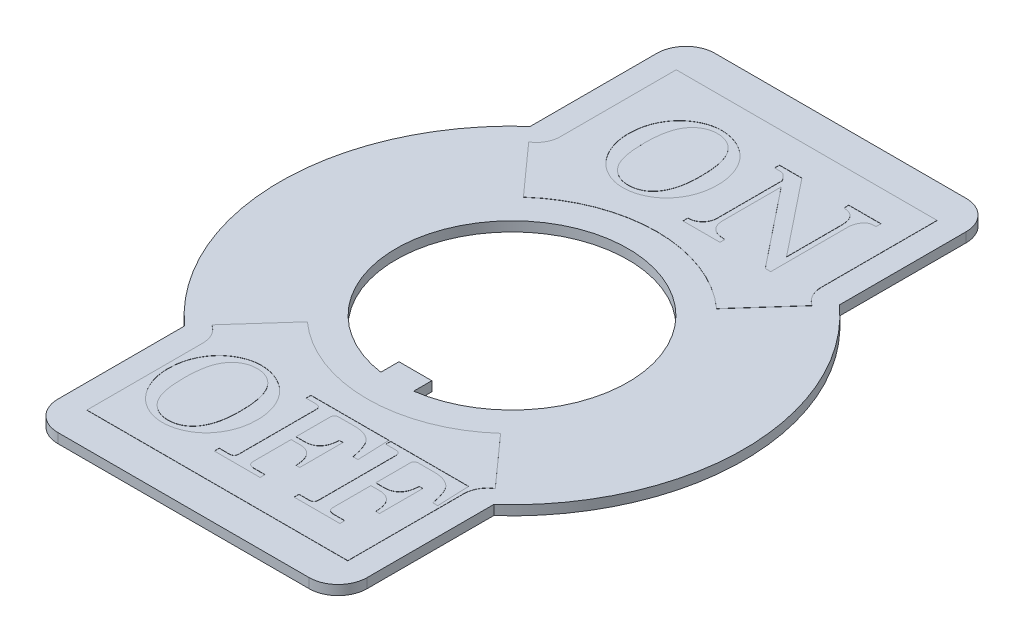
from build123d import *

# Parameters (mm, degrees)
BOSS_EXTRUDE1_DEPTH = 0.5
BOSS_EXTRUDE2_DEPTH = 0.01
CUT_EXTRUDE1_DEPTH  = 0.01


with BuildPart() as part:
    # Sketch1 → Boss-Extrude1 (new body)
    with BuildSketch(Plane(origin=(0, 0, 0), x_dir=(1, 0, 0), z_dir=(0, 1, 0))):
        with BuildLine():
            ThreePointArc((8, 15.5), (7.560660172, 16.560660172), (6.5, 17))
            Line((6.5, 17), (-6.5, 17))
            ThreePointArc((-6.5, 17), (-7.560660172, 16.560660172), (-8, 15.5))
            Line((-8, 15.5), (-8, 8.94427191))
            ThreePointArc((-8, 8.94427191), (-12, 0), (-8, -8.94427191))
            Line((-8, -8.94427191), (-8, -15.5))
            ThreePointArc((-8, -15.5), (-7.560660172, -16.560660172), (-6.5, -17))
            Line((-6.5, -17), (6.5, -17))
            ThreePointArc((6.5, -17), (7.560660172, -16.560660172), (8, -15.5))
            Line((8, -15.5), (8, -8.94427191))
            ThreePointArc((8, -8.94427191), (12, 0), (8, 8.94427191))
            Line((8, 8.94427191), (8, 15.5))
        make_face()
        with BuildLine():
            ThreePointArc((-0.85, -5.93948651), (0, 6), (0.85, -5.93948651))
            Line((0.85, -5.93948651), (0.85, -5))
            Line((0.85, -5), (-0.85, -5))
            Line((-0.85, -5), (-0.85, -5.93948651))
        make_face(mode=Mode.SUBTRACT)
    extrude(amount=BOSS_EXTRUDE1_DEPTH)

    # Sketch2 → Boss-Extrude2 (add)
    with BuildSketch(Plane(origin=(0, 0.5, 0), x_dir=(1, 0, 0), z_dir=(0, 1, 0))):
        with BuildLine():
            Line((6.75, 15.25), (-6.75, 15.25))
            Line((-6.75, 15.25), (-6.75, 9.25))
            ThreePointArc((-6.75, 9.25), (-6.905607849, 8.648947688), (-7.333333333, 8.198915917))
            Line((-7.333333333, 8.198915917), (-5, 5.590169944))
            ThreePointArc((-5, 5.590169944), (0, 7.5), (5, 5.590169944))
            Line((5, 5.590169944), (7.333333333, 8.198915917))
            ThreePointArc((7.333333333, 8.198915917), (6.905607849, 8.648947688), (6.75, 9.25))
            Line((6.75, 9.25), (6.75, 15.25))
        make_face()
        with BuildLine():
            Line((6.75, -15.25), (6.75, -9.25))
            ThreePointArc((6.75, -9.25), (6.905607849, -8.648947688), (7.333333333, -8.198915917))
            Line((7.333333333, -8.198915917), (5, -5.590169944))
            ThreePointArc((5, -5.590169944), (0, -7.5), (-5, -5.590169944))
            Line((-5, -5.590169944), (-7.333333333, -8.198915917))
            ThreePointArc((-7.333333333, -8.198915917), (-6.905607849, -8.648947688), (-6.75, -9.25))
            Line((-6.75, -9.25), (-6.75, -15.25))
            Line((-6.75, -15.25), (6.75, -15.25))
        make_face()
    extrude(amount=BOSS_EXTRUDE2_DEPTH)

    # Sketch3 → Cut-Extrude1 (cut)
    with BuildSketch(Plane(origin=(0, 0.51, 0), x_dir=(1, 0, 0), z_dir=(0, 1, 0))):
        with BuildLine():
            add(Edge.make_bspline(
                [(-2.864583333, 13.713050252), (-2.812468457, 13.712075984), (-2.709022219, 13.710142095), (-2.554972652, 13.694972601), (-2.403956212, 13.668381989), (-2.254735631, 13.633845258), (-2.10843339, 13.587084757), (-1.963809463, 13.531493439), (-1.822876473, 13.463617861), (-1.684235254, 13.387899473), (-1.551305652, 13.302190275), (-1.423973076, 13.208820824), (-1.305251073, 13.106557316), (-1.193119495, 12.99682318), (-1.089006227, 12.878643346), (-0.992800388, 12.751782549), (-0.903297195, 12.617590946), (-0.822790163, 12.47529873), (-0.749263957, 12.327546954), (-0.686522642, 12.17364314), (-0.631882058, 12.015762626), (-0.589200806, 11.852498725), (-0.55528713, 11.685286625), (-0.529656565, 11.513531463), (-0.515974008, 11.336807487), (-0.513880484, 11.217411746), (-0.512820513, 11.156960509)],
                knots=[0, 0, 0, 0, 0.00015633, 0.00031031, 0.000463778, 0.000616104, 0.000769424, 0.000924177, 0.001080537, 0.001238333, 0.001397811, 0.001554666, 0.00171165, 0.001867469, 0.002025011, 0.002183669, 0.00234479, 0.00250853, 0.002673819, 0.002839547, 0.003006788, 0.003174666, 0.003345365, 0.00351846, 0.003695299, 0.003876658, 0.003876658, 0.003876658, 0.003876658], degree=3))
            add(Edge.make_bspline(
                [(-0.512820513, 11.156960509), (-0.51373348, 11.096495605), (-0.515537073, 10.977045454), (-0.531341916, 10.800538672), (-0.554932774, 10.628552875), (-0.589103481, 10.460952248), (-0.633239722, 10.297370724), (-0.687150719, 10.138001011), (-0.751616054, 9.983675633), (-0.824492963, 9.834283927), (-0.906514185, 9.691653163), (-0.995678673, 9.556068828), (-1.092040418, 9.428597773), (-1.195399434, 9.308787155), (-1.30690416, 9.197346398), (-1.425893511, 9.094455504), (-1.552209804, 8.999654723), (-1.684248553, 8.913123543), (-1.821576978, 8.836089991), (-1.961331929, 8.7689084), (-2.103799147, 8.7127046), (-2.247407755, 8.665418002), (-2.393649003, 8.628798328), (-2.542142886, 8.604702284), (-2.692568209, 8.587338366), (-2.793753166, 8.585678454), (-2.844551282, 8.584845124)],
                knots=[0, 0, 0, 0, 0.000181359, 0.00035828, 0.000531233, 0.000701932, 0.000871037, 0.001039226, 0.001206262, 0.00137245, 0.001537556, 0.001699513, 0.001858969, 0.002016606, 0.002173835, 0.002331472, 0.002488123, 0.002647306, 0.002804713, 0.002960168, 0.003112125, 0.003263844, 0.003413485, 0.003563823, 0.003714915, 0.003867241, 0.003867241, 0.003867241, 0.003867241], degree=3))
            add(Edge.make_bspline(
                [(-2.844551282, 8.584845124), (-2.894002684, 8.585796638), (-2.992466052, 8.587691212), (-3.138714815, 8.603259452), (-3.283103116, 8.628047388), (-3.42475383, 8.66457968), (-3.564499889, 8.709401956), (-3.70175339, 8.76497853), (-3.83627043, 8.831207861), (-3.968787085, 8.906155678), (-4.096652831, 8.990749944), (-4.217744661, 9.085680944), (-4.33409882, 9.187476335), (-4.441134196, 9.300861125), (-4.545875975, 9.419285543), (-4.640116358, 9.54953776), (-4.729765374, 9.687034598), (-4.81253615, 9.832302304), (-4.886367046, 9.984697472), (-4.951748905, 10.141278074), (-5.005629541, 10.302852217), (-5.051165809, 10.467490598), (-5.084795934, 10.637003097), (-5.109904146, 10.809805286), (-5.125415266, 10.987072736), (-5.127267526, 11.106515414), (-5.128205128, 11.166976534)],
                knots=[0, 0, 0, 0, 0.000148322, 0.000295325, 0.000440727, 0.000587454, 0.000733791, 0.000880726, 0.001031237, 0.001183299, 0.001337198, 0.001490665, 0.001644629, 0.001800467, 0.001958105, 0.002118567, 0.0022822, 0.002450413, 0.00261974, 0.002789935, 0.002959073, 0.003130373, 0.003302054, 0.003477131, 0.003654052, 0.003835411, 0.003835411, 0.003835411, 0.003835411], degree=3))
            add(Edge.make_bspline(
                [(-5.128205128, 11.166976534), (-5.12717416, 11.226431314), (-5.125132533, 11.344169643), (-5.110930119, 11.518769958), (-5.087176666, 11.689077227), (-5.052789787, 11.854522497), (-5.009954847, 12.015603004), (-4.956397312, 12.171921758), (-4.894671777, 12.324464545), (-4.822570557, 12.471667642), (-4.741056379, 12.612062372), (-4.654841705, 12.747049739), (-4.558667574, 12.872402221), (-4.456715397, 12.990508553), (-4.34826719, 13.101605904), (-4.23175793, 13.203624609), (-4.108341575, 13.298081051), (-3.978558161, 13.383621168), (-3.84479677, 13.46064411), (-3.708561388, 13.527741451), (-3.571088405, 13.585020981), (-3.432727025, 13.632428977), (-3.292812682, 13.668979339), (-3.151322151, 13.693119722), (-3.008577438, 13.710566039), (-2.912713671, 13.712219899), (-2.864583333, 13.713050252)],
                knots=[0, 0, 0, 0, 0.000178356, 0.000353198, 0.000525159, 0.000693895, 0.000859838, 0.001024859, 0.001189281, 0.001353229, 0.0015161, 0.001676121, 0.001833376, 0.0019896, 0.002144003, 0.002298717, 0.002453772, 0.002609893, 0.002764689, 0.00291654, 0.003065162, 0.00321118, 0.003354996, 0.003498425, 0.003641552, 0.00378587, 0.00378587, 0.00378587, 0.00378587], degree=3))
        make_face()
        with BuildLine():
            add(Edge.make_bspline(
                [(-2.810496795, 13.456639996), (-2.864367338, 13.455339086), (-2.970431055, 13.452777772), (-3.125237932, 13.425431512), (-3.272246281, 13.383817486), (-3.411700203, 13.324889175), (-3.542705087, 13.248560704), (-3.666191688, 13.155496862), (-3.780629825, 13.04487965), (-3.8887603, 12.918645831), (-3.985364042, 12.772225919), (-4.068471624, 12.604858259), (-4.139578914, 12.417073207), (-4.19547343, 12.207432504), (-4.240739251, 11.977260711), (-4.271384157, 11.725857663), (-4.292389501, 11.453457323), (-4.294023795, 11.264843882), (-4.294871795, 11.166976534)],
                knots=[0, 0, 0, 0, 0.000161457, 0.000317887, 0.000470051, 0.000619061, 0.000770754, 0.000923799, 0.001081776, 0.001247344, 0.001421522, 0.001606518, 0.001806863, 0.002022878, 0.002256631, 0.002510068, 0.002782241, 0.003075772, 0.003075772, 0.003075772, 0.003075772], degree=3))
            add(Edge.make_bspline(
                [(-4.294871795, 11.166976534), (-4.293431121, 11.061448994), (-4.290661251, 10.858559576), (-4.272365386, 10.566917818), (-4.239630857, 10.300653677), (-4.19426956, 10.059501982), (-4.135918473, 9.843435081), (-4.064421129, 9.652181058), (-3.978375102, 9.486546743), (-3.879173122, 9.34535675), (-3.76931806, 9.226453207), (-3.653610699, 9.123806769), (-3.53247794, 9.035617151), (-3.403882619, 8.965263652), (-3.26961513, 8.909603724), (-3.128966672, 8.869176687), (-2.981537926, 8.846023553), (-2.881356061, 8.84286027), (-2.830528846, 8.84125538)],
                knots=[0, 0, 0, 0, 0.000316584, 0.000608671, 0.000876146, 0.001120906, 0.001344212, 0.001546786, 0.001732263, 0.001902609, 0.002062828, 0.002216792, 0.002366061, 0.002511307, 0.002655461, 0.002801297, 0.002949334, 0.003101789, 0.003101789, 0.003101789, 0.003101789], degree=3))
            add(Edge.make_bspline(
                [(-2.830528846, 8.84125538), (-2.794786657, 8.842179785), (-2.72450079, 8.843997596), (-2.620286136, 8.85379338), (-2.519567555, 8.871956584), (-2.422041264, 8.896813843), (-2.328164813, 8.929514729), (-2.236839276, 8.967847139), (-2.149883974, 9.015891752), (-2.065055415, 9.068525702), (-1.984418385, 9.130058039), (-1.908437235, 9.200552602), (-1.835864601, 9.279057767), (-1.767906456, 9.366191535), (-1.704892457, 9.461966101), (-1.645472788, 9.565562592), (-1.590781054, 9.677853508), (-1.53949866, 9.798352215), (-1.492831783, 9.927787875), (-1.454911439, 10.067436093), (-1.419824888, 10.216169616), (-1.394140638, 10.375306829), (-1.371334164, 10.543522053), (-1.356994196, 10.721728193), (-1.347758849, 10.909464653), (-1.34669694, 11.038091684), (-1.346153846, 11.103875573)],
                knots=[0, 0, 0, 0, 0.000107246, 0.000210896, 0.000313652, 0.000413983, 0.000512492, 0.000611655, 0.000710698, 0.00081018, 0.000910944, 0.001014434, 0.001120755, 0.001231354, 0.001345528, 0.00146442, 0.001589395, 0.001719992, 0.001857168, 0.002001767, 0.002153865, 0.0023154, 0.002485106, 0.002663025, 0.002851542, 0.00304888, 0.00304888, 0.00304888, 0.00304888], degree=3))
            add(Edge.make_bspline(
                [(-1.346153846, 11.103875573), (-1.3468274, 11.175327478), (-1.348137173, 11.31427088), (-1.355472419, 11.516773642), (-1.370981782, 11.707454808), (-1.390638707, 11.885870334), (-1.415038718, 12.052544539), (-1.447497155, 12.206448949), (-1.483822939, 12.34919998), (-1.527340026, 12.480126024), (-1.575635139, 12.601145669), (-1.628648945, 12.713647777), (-1.686815468, 12.818086891), (-1.749576902, 12.914560891), (-1.818483552, 13.002192246), (-1.89105074, 13.08231569), (-1.969164303, 13.154365994), (-2.051879258, 13.218001936), (-2.138344762, 13.273893941), (-2.226593465, 13.323655729), (-2.317863626, 13.364606569), (-2.411728887, 13.397844592), (-2.507872055, 13.423723886), (-2.606525803, 13.443149001), (-2.707752319, 13.454076417), (-2.776083891, 13.455781359), (-2.810496795, 13.456639996)],
                knots=[0, 0, 0, 0, 0.000214364, 0.000416846, 0.000607743, 0.000788145, 0.000955296, 0.001112838, 0.001259814, 0.001396961, 0.001526412, 0.001650517, 0.001769788, 0.001884798, 0.001995397, 0.002103871, 0.002208777, 0.002313754, 0.002416544, 0.002517428, 0.002617397, 0.002716237, 0.002815855, 0.00291584, 0.0030176, 0.003120843, 0.003120843, 0.003120843, 0.003120843], degree=3))
        make_face(mode=Mode.SUBTRACT)
        with BuildLine():
            Line((0.192307692, 13.648947688), (1.355168269, 13.648947688))
            Line((1.355168269, 13.648947688), (4.487179487, 9.720662432))
            Line((4.487179487, 9.720662432), (4.487179487, 12.561207304))
            add(Edge.make_bspline(
                [(4.487179487, 12.561207304), (4.486624787, 12.595946314), (4.485550715, 12.663211769), (4.476716763, 12.760339106), (4.46121445, 12.850202882), (4.44223679, 12.933793997), (4.414478561, 13.009837195), (4.383290718, 13.079853904), (4.343476631, 13.141499745), (4.312936401, 13.178150398), (4.297876603, 13.196223329)],
                knots=[0, 0, 0, 0, 0.00010421, 0.000201783, 0.000292183, 0.000377695, 0.000458478, 0.000534659, 0.000607177, 0.000677724, 0.000677724, 0.000677724, 0.000677724], degree=3))
            add(Edge.make_bspline(
                [(4.297876603, 13.196223329), (4.282831592, 13.211251544), (4.252612174, 13.241437227), (4.201087874, 13.280973307), (4.143612271, 13.313264341), (4.082213685, 13.342494203), (4.014148114, 13.36268904), (3.941565971, 13.37884088), (3.863426424, 13.388759494), (3.809788312, 13.391249707), (3.782051282, 13.392537432)],
                knots=[0, 0, 0, 0, 6.3757e-05, 0.000128063, 0.000194032, 0.000261259, 0.000331585, 0.000406438, 0.000484209, 0.000567493, 0.000567493, 0.000567493, 0.000567493], degree=3))
            Line((3.782051282, 13.392537432), (3.782051282, 13.648947688))
            Line((3.782051282, 13.648947688), (5.448717949, 13.648947688))
            Line((5.448717949, 13.648947688), (5.448717949, 13.392537432))
            add(Edge.make_bspline(
                [(5.448717949, 13.392537432), (5.40830535, 13.39145269), (5.332586338, 13.389420264), (5.226323457, 13.377904241), (5.136936702, 13.353699968), (5.06021957, 13.321895478), (4.997119481, 13.273037628), (4.937523097, 13.213577167), (4.885963966, 13.135754452), (4.836221564, 13.047245768), (4.794166, 12.948490663), (4.765949779, 12.84251325), (4.746775402, 12.732504974), (4.744663169, 12.657445213), (4.743589744, 12.619300252)],
                knots=[0, 0, 0, 0, 0.000121297, 0.000227269, 0.000319595, 0.000398513, 0.000474436, 0.000557304, 0.000650107, 0.000753229, 0.000861864, 0.00097097, 0.001081623, 0.001195964, 0.001195964, 0.001195964, 0.001195964], degree=3))
            Line((4.743589744, 12.619300252), (4.743589744, 8.648947688))
            Line((4.743589744, 8.648947688), (4.459134615, 8.648947688))
            Line((4.459134615, 8.648947688), (1.217948718, 12.713450893))
            Line((1.217948718, 12.713450893), (1.217948718, 9.717657624))
            add(Edge.make_bspline(
                [(1.217948718, 9.717657624), (1.218296578, 9.684897634), (1.218973172, 9.62117882), (1.230749382, 9.529172976), (1.247165687, 9.443182804), (1.271432417, 9.364155351), (1.301113742, 9.29068958), (1.339849959, 9.224720196), (1.383642723, 9.163845398), (1.43569531, 9.110086915), (1.494875117, 9.062817081), (1.562091331, 9.022966094), (1.635570164, 8.987382379), (1.71727022, 8.95868795), (1.806340408, 8.935496073), (1.903022288, 8.920388937), (2.006613147, 8.908736842), (2.078289851, 8.906510263), (2.115384615, 8.905357945)],
                knots=[0, 0, 0, 0, 9.8203e-05, 0.000191007, 0.000277829, 0.000360526, 0.000438651, 0.000514931, 0.000589455, 0.000663125, 0.000738678, 0.000815977, 0.000897064, 0.000983236, 0.001075308, 0.001172788, 0.00127654, 0.00138783, 0.00138783, 0.00138783, 0.00138783], degree=3))
            Line((2.115384615, 8.905357945), (2.115384615, 8.648947688))
            Line((2.115384615, 8.648947688), (0.192307692, 8.648947688))
            Line((0.192307692, 8.648947688), (0.192307692, 8.905357945))
            add(Edge.make_bspline(
                [(0.192307692, 8.905357945), (0.22106758, 8.906840271), (0.277524834, 8.90975016), (0.359718592, 8.922880489), (0.437098367, 8.942973226), (0.509819398, 8.969219664), (0.578075023, 9.001108145), (0.641926263, 9.039600463), (0.701343603, 9.084643091), (0.772271116, 9.153926021), (0.849045815, 9.24988305), (0.913932154, 9.381479678), (0.954574072, 9.524616386), (0.959184801, 9.624567703), (0.961538462, 9.675590316)],
                knots=[0, 0, 0, 0, 8.6347e-05, 0.000169504, 0.000249187, 0.00032586, 0.000401134, 0.000474825, 0.000549146, 0.000624233, 0.000771904, 0.000915242, 0.00106177, 0.00121457, 0.00121457, 0.00121457, 0.00121457], degree=3))
            Line((0.961538462, 9.675590316), (0.961538462, 13.035966919))
            Line((0.961538462, 13.035966919), (0.89443109, 13.121103137))
            add(Edge.make_bspline(
                [(0.89443109, 13.121103137), (0.871044623, 13.149776427), (0.828680691, 13.201717291), (0.767777964, 13.267366266), (0.718492584, 13.316398433), (0.68508654, 13.336873459), (0.671073718, 13.345462111)],
                knots=[0, 0, 0, 0, 0.000110929, 0.000200946, 0.000268996, 0.000318166, 0.000318166, 0.000318166, 0.000318166], degree=3))
            add(Edge.make_bspline(
                [(0.671073718, 13.345462111), (0.653913124, 13.353072618), (0.618197195, 13.368912183), (0.557680137, 13.381627356), (0.490761519, 13.391146514), (0.443419924, 13.392059911), (0.418669872, 13.392537432)],
                knots=[0, 0, 0, 0, 5.617e-05, 0.000116906, 0.000184616, 0.000258795, 0.000258795, 0.000258795, 0.000258795], degree=3))
            Line((0.418669872, 13.392537432), (0.192307692, 13.392537432))
            Line((0.192307692, 13.392537432), (0.192307692, 13.648947688))
        make_face()
        with BuildLine():
            add(Edge.make_bspline(
                [(-4.250079566, -8.726817902), (-4.197964689, -8.72779217), (-4.094518452, -8.729726059), (-3.940468884, -8.744895553), (-3.789452444, -8.771486165), (-3.640231863, -8.806022896), (-3.493929623, -8.852783397), (-3.349305695, -8.908374715), (-3.208372705, -8.976250293), (-3.069731486, -9.051968681), (-2.936801884, -9.137677879), (-2.809469309, -9.23104733), (-2.690747305, -9.333310837), (-2.578615728, -9.443044974), (-2.474502459, -9.561224807), (-2.37829662, -9.688085605), (-2.288793428, -9.822277208), (-2.208286395, -9.964569424), (-2.134760189, -10.1123212), (-2.072018874, -10.266225014), (-2.017378291, -10.424105528), (-1.974697038, -10.587369429), (-1.940783363, -10.754581529), (-1.915152797, -10.926336691), (-1.90147024, -11.103060667), (-1.899376717, -11.222456408), (-1.898316745, -11.282907645)],
                knots=[0, 0, 0, 0, 0.00015633, 0.00031031, 0.000463778, 0.000616104, 0.000769424, 0.000924177, 0.001080537, 0.001238333, 0.001397811, 0.001554666, 0.00171165, 0.001867469, 0.002025011, 0.002183669, 0.00234479, 0.00250853, 0.002673819, 0.002839547, 0.003006788, 0.003174666, 0.003345365, 0.00351846, 0.003695299, 0.003876658, 0.003876658, 0.003876658, 0.003876658], degree=3))
            add(Edge.make_bspline(
                [(-1.898316745, -11.282907645), (-1.899229712, -11.343372549), (-1.901033305, -11.4628227), (-1.916838148, -11.639329482), (-1.940429007, -11.811315279), (-1.974599714, -11.978915906), (-2.018735955, -12.142497429), (-2.072646951, -12.301867143), (-2.137112286, -12.456192521), (-2.209989196, -12.605584227), (-2.292010417, -12.748214991), (-2.381174905, -12.883799326), (-2.47753665, -13.011270381), (-2.580895666, -13.131080999), (-2.692400393, -13.242521756), (-2.811389744, -13.345412649), (-2.937706036, -13.440213431), (-3.069744785, -13.526744611), (-3.20707321, -13.603778163), (-3.346828161, -13.670959754), (-3.489295379, -13.727163554), (-3.632903988, -13.774450152), (-3.779145235, -13.811069826), (-3.927639118, -13.83516587), (-4.078064441, -13.852529788), (-4.179249399, -13.8541897), (-4.230047514, -13.85502303)],
                knots=[0, 0, 0, 0, 0.000181359, 0.00035828, 0.000531233, 0.000701932, 0.000871037, 0.001039226, 0.001206262, 0.00137245, 0.001537556, 0.001699513, 0.001858969, 0.002016606, 0.002173835, 0.002331472, 0.002488123, 0.002647306, 0.002804713, 0.002960168, 0.003112125, 0.003263844, 0.003413485, 0.003563823, 0.003714915, 0.003867241, 0.003867241, 0.003867241, 0.003867241], degree=3))
            add(Edge.make_bspline(
                [(-4.230047514, -13.85502303), (-4.279498916, -13.854071515), (-4.377962285, -13.852176942), (-4.524211048, -13.836608702), (-4.668599348, -13.811820766), (-4.810250062, -13.775288474), (-4.949996121, -13.730466198), (-5.087249622, -13.674889624), (-5.221766663, -13.608660293), (-5.354283317, -13.533712476), (-5.482149063, -13.449118209), (-5.603240893, -13.35418721), (-5.719595052, -13.252391819), (-5.826630429, -13.139007029), (-5.931372207, -13.020582611), (-6.02561259, -12.890330393), (-6.115261607, -12.752833556), (-6.198032383, -12.60756585), (-6.271863278, -12.455170682), (-6.337245138, -12.29859008), (-6.391125773, -12.137015937), (-6.436662041, -11.972377556), (-6.470292167, -11.802865057), (-6.495400378, -11.630062868), (-6.510911498, -11.452795418), (-6.512763758, -11.33335274), (-6.513701361, -11.27289162)],
                knots=[0, 0, 0, 0, 0.000148322, 0.000295325, 0.000440727, 0.000587454, 0.000733791, 0.000880726, 0.001031237, 0.001183299, 0.001337198, 0.001490665, 0.001644629, 0.001800467, 0.001958105, 0.002118567, 0.0022822, 0.002450413, 0.00261974, 0.002789935, 0.002959073, 0.003130373, 0.003302054, 0.003477131, 0.003654052, 0.003835411, 0.003835411, 0.003835411, 0.003835411], degree=3))
            add(Edge.make_bspline(
                [(-6.513701361, -11.27289162), (-6.512670392, -11.21343684), (-6.510628765, -11.095698511), (-6.496426352, -10.921098196), (-6.472672899, -10.750790927), (-6.438286019, -10.585345657), (-6.39545108, -10.42426515), (-6.341893545, -10.267946396), (-6.280168009, -10.115403609), (-6.208066789, -9.968200511), (-6.126552611, -9.827805782), (-6.040337937, -9.692818415), (-5.944163806, -9.567465933), (-5.842211629, -9.449359601), (-5.733763423, -9.33826225), (-5.617254162, -9.236243545), (-5.493837808, -9.141787103), (-5.364054393, -9.056246986), (-5.230293002, -8.979224044), (-5.094057621, -8.912126702), (-4.956584637, -8.854847173), (-4.818223258, -8.807439177), (-4.678308915, -8.770888815), (-4.536818383, -8.746748432), (-4.39407367, -8.729302115), (-4.298209903, -8.727648255), (-4.250079566, -8.726817902)],
                knots=[0, 0, 0, 0, 0.000178356, 0.000353198, 0.000525159, 0.000693895, 0.000859838, 0.001024859, 0.001189281, 0.001353229, 0.0015161, 0.001676121, 0.001833376, 0.0019896, 0.002144003, 0.002298717, 0.002453772, 0.002609893, 0.002764689, 0.00291654, 0.003065162, 0.00321118, 0.003354996, 0.003498425, 0.003641552, 0.00378587, 0.00378587, 0.00378587, 0.00378587], degree=3))
        make_face()
        with BuildLine():
            add(Edge.make_bspline(
                [(-4.195993027, -8.983228158), (-4.249863571, -8.984529068), (-4.355927288, -8.987090382), (-4.510734164, -9.014436642), (-4.657742514, -9.056050668), (-4.797196435, -9.114978979), (-4.92820132, -9.19130745), (-5.05168792, -9.284371291), (-5.166126058, -9.394988504), (-5.274256532, -9.521222323), (-5.370860274, -9.667642235), (-5.453967856, -9.835009895), (-5.525075147, -10.022794947), (-5.580969662, -10.23243565), (-5.626235484, -10.462607443), (-5.656880389, -10.714010491), (-5.677885733, -10.986410831), (-5.679520028, -11.175024272), (-5.680368027, -11.27289162)],
                knots=[0, 0, 0, 0, 0.000161457, 0.000317887, 0.000470051, 0.000619061, 0.000770754, 0.000923799, 0.001081776, 0.001247344, 0.001421522, 0.001606518, 0.001806863, 0.002022878, 0.002256631, 0.002510068, 0.002782241, 0.003075772, 0.003075772, 0.003075772, 0.003075772], degree=3))
            add(Edge.make_bspline(
                [(-5.680368027, -11.27289162), (-5.678927353, -11.37841916), (-5.676157483, -11.581308578), (-5.657861619, -11.872950336), (-5.625127089, -12.139214477), (-5.579765793, -12.380366172), (-5.521414705, -12.596433073), (-5.449917361, -12.787687096), (-5.363871334, -12.953321411), (-5.264669354, -13.094511404), (-5.154814292, -13.213414947), (-5.039106931, -13.316061385), (-4.917974173, -13.404251003), (-4.789378851, -13.474604502), (-4.655111362, -13.53026443), (-4.514462904, -13.570691467), (-4.367034158, -13.593844601), (-4.266852294, -13.597007884), (-4.216025078, -13.598612773)],
                knots=[0, 0, 0, 0, 0.000316584, 0.000608671, 0.000876146, 0.001120906, 0.001344212, 0.001546786, 0.001732263, 0.001902609, 0.002062828, 0.002216792, 0.002366061, 0.002511307, 0.002655461, 0.002801297, 0.002949334, 0.003101789, 0.003101789, 0.003101789, 0.003101789], degree=3))
            add(Edge.make_bspline(
                [(-4.216025078, -13.598612773), (-4.18028289, -13.597688369), (-4.109997023, -13.595870558), (-4.005782369, -13.586074774), (-3.905063788, -13.56791157), (-3.807537496, -13.54305431), (-3.713661045, -13.510353424), (-3.622335509, -13.472021015), (-3.535380207, -13.423976402), (-3.450551648, -13.371342452), (-3.369914617, -13.309810115), (-3.293933468, -13.239315552), (-3.221360834, -13.160810387), (-3.153402688, -13.073676619), (-3.09038869, -12.977902052), (-3.03096902, -12.874305562), (-2.976277286, -12.762014646), (-2.924994892, -12.641515939), (-2.878328015, -12.512080279), (-2.840407671, -12.372432061), (-2.80532112, -12.223698538), (-2.77963687, -12.064561325), (-2.756830396, -11.896346101), (-2.742490429, -11.718139961), (-2.733255081, -11.530403501), (-2.732193172, -11.40177647), (-2.731650078, -11.335992581)],
                knots=[0, 0, 0, 0, 0.000107246, 0.000210896, 0.000313652, 0.000413983, 0.000512492, 0.000611655, 0.000710698, 0.00081018, 0.000910944, 0.001014434, 0.001120755, 0.001231354, 0.001345528, 0.00146442, 0.001589395, 0.001719992, 0.001857168, 0.002001767, 0.002153865, 0.0023154, 0.002485106, 0.002663025, 0.002851542, 0.00304888, 0.00304888, 0.00304888, 0.00304888], degree=3))
            add(Edge.make_bspline(
                [(-2.731650078, -11.335992581), (-2.732323632, -11.264540676), (-2.733633406, -11.125597273), (-2.740968651, -10.923094512), (-2.756478015, -10.732413346), (-2.77613494, -10.55399782), (-2.80053495, -10.387323615), (-2.832993387, -10.233419205), (-2.869319171, -10.090668174), (-2.912836259, -9.95974213), (-2.961131371, -9.838722485), (-3.014145178, -9.726220377), (-3.0723117, -9.621781263), (-3.135073134, -9.525307263), (-3.203979784, -9.437675908), (-3.276546972, -9.357552464), (-3.354660535, -9.28550216), (-3.43737549, -9.221866218), (-3.523840994, -9.165974213), (-3.612089697, -9.116212425), (-3.703359858, -9.075261585), (-3.79722512, -9.042023562), (-3.893368287, -9.016144268), (-3.992022035, -8.996719153), (-4.093248552, -8.985791737), (-4.161580123, -8.984086795), (-4.195993027, -8.983228158)],
                knots=[0, 0, 0, 0, 0.000214364, 0.000416846, 0.000607743, 0.000788145, 0.000955296, 0.001112838, 0.001259814, 0.001396961, 0.001526412, 0.001650517, 0.001769788, 0.001884798, 0.001995397, 0.002103871, 0.002208777, 0.002313754, 0.002416544, 0.002517428, 0.002617397, 0.002716237, 0.002815855, 0.00291584, 0.0030176, 0.003120843, 0.003120843, 0.003120843, 0.003120843], degree=3))
        make_face(mode=Mode.SUBTRACT)
        with BuildLine():
            Line((-1.616265463, -8.790920466), (2.422196075, -8.790920466))
            Line((2.422196075, -8.790920466), (2.486298639, -10.457587132))
            Line((2.486298639, -10.457587132), (2.229888383, -10.457587132))
            add(Edge.make_bspline(
                [(2.229888383, -10.457587132), (2.21662899, -10.389725271), (2.191194684, -10.259551945), (2.147804562, -10.073726601), (2.098635615, -9.906769558), (2.047228634, -9.757897022), (1.991587087, -9.627941083), (1.931325232, -9.516964695), (1.868205297, -9.422860754), (1.818630707, -9.371903176), (1.79519287, -9.347811491)],
                knots=[0, 0, 0, 0, 0.000207431, 0.000397896, 0.000572215, 0.000729336, 0.000870192, 0.000995693, 0.001107944, 0.001208603, 0.001208603, 0.001208603, 0.001208603], degree=3))
            add(Edge.make_bspline(
                [(1.79519287, -9.347811491), (1.767696413, -9.323730329), (1.712231491, -9.275154623), (1.618057329, -9.214699064), (1.516694764, -9.16203192), (1.406304098, -9.120169202), (1.287721349, -9.086835559), (1.160179991, -9.064583311), (1.024288711, -9.050161237), (0.93084908, -9.048292841), (0.882732934, -9.047330722)],
                knots=[0, 0, 0, 0, 0.000109519, 0.000220917, 0.0003347, 0.000451699, 0.000574423, 0.000703695, 0.000839637, 0.000983955, 0.000983955, 0.000983955, 0.000983955], degree=3))
            Line((0.882732934, -9.047330722), (0.083454088, -9.047330722))
            add(Edge.make_bspline(
                [(0.083454088, -9.047330722), (0.064997692, -9.047565819), (0.030693382, -9.048002786), (-0.016491905, -9.059866542), (-0.056789156, -9.076118701), (-0.088551683, -9.101245159), (-0.114328101, -9.132155935), (-0.128892874, -9.171697751), (-0.141228512, -9.216189111), (-0.141671713, -9.24854191), (-0.141906489, -9.265680081)],
                knots=[0, 0, 0, 0, 5.517e-05, 0.000102543, 0.000145155, 0.000184422, 0.000222903, 0.0002642, 0.000309627, 0.000360797, 0.000360797, 0.000360797, 0.000360797], degree=3))
            Line((-0.141906489, -9.265680081), (-0.141906489, -11.034510209))
            Line((-0.141906489, -11.034510209), (0.305809857, -11.034510209))
            add(Edge.make_bspline(
                [(0.305809857, -11.034510209), (0.336229316, -11.033715592), (0.395603083, -11.03216463), (0.482058413, -11.020823494), (0.563817525, -11.00331798), (0.640470791, -10.976703419), (0.712739893, -10.943790882), (0.780673427, -10.903666218), (0.842763368, -10.854722344), (0.901509114, -10.799978475), (0.953378218, -10.736281825), (1.000163781, -10.66538972), (1.040148164, -10.586077053), (1.072613301, -10.49850534), (1.100286159, -10.40358174), (1.11937705, -10.300513954), (1.133833547, -10.189503253), (1.137990584, -10.112747288), (1.140144793, -10.072971748)],
                knots=[0, 0, 0, 0, 9.1234e-05, 0.000178073, 0.000261182, 0.000341635, 0.000420965, 0.000499122, 0.000577656, 0.000657716, 0.000739535, 0.000823431, 0.000912122, 0.00100532, 0.001103277, 0.001208369, 0.001319434, 0.001438894, 0.001438894, 0.001438894, 0.001438894], degree=3))
            Line((1.140144793, -10.072971748), (1.332452486, -10.072971748))
            Line((1.332452486, -10.072971748), (1.332452486, -12.316561491))
            Line((1.332452486, -12.316561491), (1.140144793, -12.316561491))
            add(Edge.make_bspline(
                [(1.140144793, -12.316561491), (1.137649942, -12.272114657), (1.132836031, -12.186352809), (1.117589848, -12.062628957), (1.097181533, -11.948733458), (1.069929007, -11.844632888), (1.037582746, -11.75045368), (0.99803873, -11.666326496), (0.953306667, -11.591645228), (0.901730194, -11.527002491), (0.844786391, -11.47138511), (0.783233, -11.422654532), (0.716238307, -11.381782171), (0.643962741, -11.348325071), (0.566784061, -11.322169743), (0.484060023, -11.304593863), (0.396599338, -11.293271888), (0.336562171, -11.291716942), (0.305809857, -11.290920466)],
                knots=[0, 0, 0, 0, 0.000133518, 0.000257628, 0.000373731, 0.000480382, 0.000580166, 0.000672019, 0.000758766, 0.000840733, 0.00091935, 0.000997096, 0.001075771, 0.001154191, 0.001235592, 0.001319679, 0.001407512, 0.001499747, 0.001499747, 0.001499747, 0.001499747], degree=3))
            Line((0.305809857, -11.290920466), (-0.141906489, -11.290920466))
            Line((-0.141906489, -11.290920466), (-0.141906489, -13.223011812))
            add(Edge.make_bspline(
                [(-0.141906489, -13.223011812), (-0.141229131, -13.249505715), (-0.139962332, -13.299054816), (-0.123593555, -13.366779152), (-0.099357384, -13.4235403), (-0.060660858, -13.467264602), (-0.008941457, -13.499400818), (0.057043663, -13.518567574), (0.136204673, -13.533554142), (0.194201004, -13.534173836), (0.225681652, -13.534510209)],
                knots=[0, 0, 0, 0, 7.9285e-05, 0.000148279, 0.000207881, 0.00026253, 0.000320606, 0.000388071, 0.000467445, 0.00056168, 0.00056168, 0.00056168, 0.00056168], degree=3))
            Line((0.225681652, -13.534510209), (0.755529409, -13.534510209))
            Line((0.755529409, -13.534510209), (0.755529409, -13.790920466))
            Line((0.755529409, -13.790920466), (-1.616265463, -13.790920466))
            Line((-1.616265463, -13.790920466), (-1.616265463, -13.534510209))
            Line((-1.616265463, -13.534510209), (-1.122475399, -13.534510209))
            add(Edge.make_bspline(
                [(-1.122475399, -13.534510209), (-1.09937441, -13.533864788), (-1.056149763, -13.53265713), (-0.996918584, -13.520887194), (-0.947666885, -13.502104414), (-0.908688624, -13.47405833), (-0.879004275, -13.436052273), (-0.86142593, -13.387752206), (-0.848615078, -13.33118267), (-0.847588947, -13.290213158), (-0.847034694, -13.268083927)],
                knots=[0, 0, 0, 0, 6.9227e-05, 0.000129531, 0.000180307, 0.000226185, 0.000271865, 0.000322641, 0.000379025, 0.000445252, 0.000445252, 0.000445252, 0.000445252], degree=3))
            Line((-0.847034694, -13.268083927), (-0.847034694, -9.296729761))
            add(Edge.make_bspline(
                [(-0.847034694, -9.296729761), (-0.847595797, -9.275946417), (-0.848649746, -9.236907977), (-0.861693264, -9.183108541), (-0.882537571, -9.138445001), (-0.913275491, -9.103098337), (-0.955212911, -9.077494352), (-1.007842024, -9.058481059), (-1.073134306, -9.049887892), (-1.120126683, -9.048227615), (-1.145512258, -9.047330722)],
                knots=[0, 0, 0, 0, 6.2228e-05, 0.000116887, 0.000164818, 0.00020882, 0.000255219, 0.00031067, 0.00037555, 0.000451778, 0.000451778, 0.000451778, 0.000451778], degree=3))
            Line((-1.145512258, -9.047330722), (-1.616265463, -9.047330722))
            Line((-1.616265463, -9.047330722), (-1.616265463, -8.790920466))
        make_face()
        with BuildLine():
            Line((2.511939665, -8.790920466), (6.550401204, -8.790920466))
            Line((6.550401204, -8.790920466), (6.614503768, -10.457587132))
            Line((6.614503768, -10.457587132), (6.358093511, -10.457587132))
            add(Edge.make_bspline(
                [(6.358093511, -10.457587132), (6.344834118, -10.389725271), (6.319399812, -10.259551945), (6.276009691, -10.073726601), (6.226840743, -9.906769558), (6.175433762, -9.757897022), (6.119792216, -9.627941083), (6.05953036, -9.516964695), (5.996410426, -9.422860754), (5.946835835, -9.371903176), (5.923397998, -9.347811491)],
                knots=[0, 0, 0, 0, 0.000207431, 0.000397896, 0.000572215, 0.000729336, 0.000870192, 0.000995693, 0.001107944, 0.001208603, 0.001208603, 0.001208603, 0.001208603], degree=3))
            add(Edge.make_bspline(
                [(5.923397998, -9.347811491), (5.895901542, -9.323730329), (5.84043662, -9.275154623), (5.746262457, -9.214699064), (5.644899892, -9.16203192), (5.534509226, -9.120169202), (5.415926477, -9.086835559), (5.288385119, -9.064583311), (5.15249384, -9.050161237), (5.059054208, -9.048292841), (5.010938063, -9.047330722)],
                knots=[0, 0, 0, 0, 0.000109519, 0.000220917, 0.0003347, 0.000451699, 0.000574423, 0.000703695, 0.000839637, 0.000983955, 0.000983955, 0.000983955, 0.000983955], degree=3))
            Line((5.010938063, -9.047330722), (4.211659216, -9.047330722))
            add(Edge.make_bspline(
                [(4.211659216, -9.047330722), (4.19320282, -9.047565819), (4.15889851, -9.048002786), (4.111713224, -9.059866542), (4.071415973, -9.076118701), (4.039653445, -9.101245159), (4.013877027, -9.132155935), (3.999312254, -9.171697751), (3.986976616, -9.216189111), (3.986533415, -9.24854191), (3.986298639, -9.265680081)],
                knots=[0, 0, 0, 0, 5.517e-05, 0.000102543, 0.000145155, 0.000184422, 0.000222903, 0.0002642, 0.000309627, 0.000360797, 0.000360797, 0.000360797, 0.000360797], degree=3))
            Line((3.986298639, -9.265680081), (3.986298639, -11.034510209))
            Line((3.986298639, -11.034510209), (4.434014986, -11.034510209))
            add(Edge.make_bspline(
                [(4.434014986, -11.034510209), (4.464434444, -11.033715592), (4.523808211, -11.03216463), (4.610263541, -11.020823494), (4.692022653, -11.00331798), (4.768675919, -10.976703419), (4.840945022, -10.943790882), (4.908878555, -10.903666218), (4.970968496, -10.854722344), (5.029714243, -10.799978475), (5.081583346, -10.736281825), (5.128368909, -10.66538972), (5.168353292, -10.586077053), (5.200818429, -10.49850534), (5.228491287, -10.40358174), (5.247582179, -10.300513954), (5.262038675, -10.189503253), (5.266195712, -10.112747288), (5.268349922, -10.072971748)],
                knots=[0, 0, 0, 0, 9.1234e-05, 0.000178073, 0.000261182, 0.000341635, 0.000420965, 0.000499122, 0.000577656, 0.000657716, 0.000739535, 0.000823431, 0.000912122, 0.00100532, 0.001103277, 0.001208369, 0.001319434, 0.001438894, 0.001438894, 0.001438894, 0.001438894], degree=3))
            Line((5.268349922, -10.072971748), (5.460657614, -10.072971748))
            Line((5.460657614, -10.072971748), (5.460657614, -12.316561491))
            Line((5.460657614, -12.316561491), (5.268349922, -12.316561491))
            add(Edge.make_bspline(
                [(5.268349922, -12.316561491), (5.26585507, -12.272114657), (5.261041159, -12.186352809), (5.245794976, -12.062628957), (5.225386661, -11.948733458), (5.198134135, -11.844632888), (5.165787875, -11.75045368), (5.126243859, -11.666326496), (5.081511795, -11.591645228), (5.029935322, -11.527002491), (4.972991519, -11.47138511), (4.911438128, -11.422654532), (4.844443435, -11.381782171), (4.77216787, -11.348325071), (4.694989189, -11.322169743), (4.612265151, -11.304593863), (4.524804466, -11.293271888), (4.4647673, -11.291716942), (4.434014986, -11.290920466)],
                knots=[0, 0, 0, 0, 0.000133518, 0.000257628, 0.000373731, 0.000480382, 0.000580166, 0.000672019, 0.000758766, 0.000840733, 0.00091935, 0.000997096, 0.001075771, 0.001154191, 0.001235592, 0.001319679, 0.001407512, 0.001499747, 0.001499747, 0.001499747, 0.001499747], degree=3))
            Line((4.434014986, -11.290920466), (3.986298639, -11.290920466))
            Line((3.986298639, -11.290920466), (3.986298639, -13.223011812))
            add(Edge.make_bspline(
                [(3.986298639, -13.223011812), (3.986975997, -13.249505715), (3.988242797, -13.299054816), (4.004611573, -13.366779152), (4.028847744, -13.4235403), (4.06754427, -13.467264602), (4.119263671, -13.499400818), (4.185248791, -13.518567574), (4.264409802, -13.533554142), (4.322406132, -13.534173836), (4.35388678, -13.534510209)],
                knots=[0, 0, 0, 0, 7.9285e-05, 0.000148279, 0.000207881, 0.00026253, 0.000320606, 0.000388071, 0.000467445, 0.00056168, 0.00056168, 0.00056168, 0.00056168], degree=3))
            Line((4.35388678, -13.534510209), (4.883734537, -13.534510209))
            Line((4.883734537, -13.534510209), (4.883734537, -13.790920466))
            Line((4.883734537, -13.790920466), (2.511939665, -13.790920466))
            Line((2.511939665, -13.790920466), (2.511939665, -13.534510209))
            Line((2.511939665, -13.534510209), (3.005729729, -13.534510209))
            add(Edge.make_bspline(
                [(3.005729729, -13.534510209), (3.028830718, -13.533864788), (3.072055365, -13.53265713), (3.131286545, -13.520887194), (3.180538243, -13.502104414), (3.219516504, -13.47405833), (3.249200854, -13.436052273), (3.266779198, -13.387752206), (3.27959005, -13.33118267), (3.280616181, -13.290213158), (3.281170434, -13.268083927)],
                knots=[0, 0, 0, 0, 6.9227e-05, 0.000129531, 0.000180307, 0.000226185, 0.000271865, 0.000322641, 0.000379025, 0.000445252, 0.000445252, 0.000445252, 0.000445252], degree=3))
            Line((3.281170434, -13.268083927), (3.281170434, -9.296729761))
            add(Edge.make_bspline(
                [(3.281170434, -9.296729761), (3.280609331, -9.275946417), (3.279555382, -9.236907977), (3.266511864, -9.183108541), (3.245667557, -9.138445001), (3.214929637, -9.103098337), (3.172992217, -9.077494352), (3.120363104, -9.058481059), (3.055070822, -9.049887892), (3.008078446, -9.048227615), (2.98269287, -9.047330722)],
                knots=[0, 0, 0, 0, 6.2228e-05, 0.000116887, 0.000164818, 0.00020882, 0.000255219, 0.00031067, 0.00037555, 0.000451778, 0.000451778, 0.000451778, 0.000451778], degree=3))
            Line((2.98269287, -9.047330722), (2.511939665, -9.047330722))
            Line((2.511939665, -9.047330722), (2.511939665, -8.790920466))
        make_face()
    extrude(amount=-CUT_EXTRUDE1_DEPTH, mode=Mode.SUBTRACT)


solid = part.part
